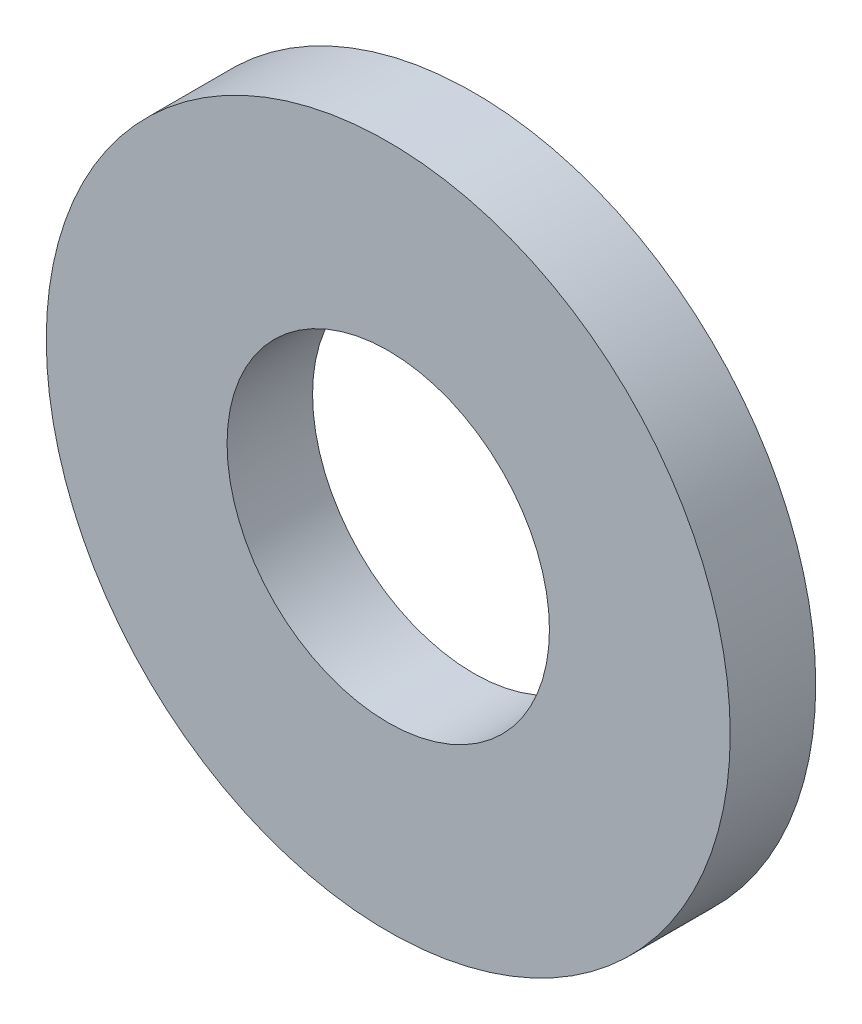
from build123d import *

# Parameters (mm, degrees)
SKETCH1_R           = 6.35
SKETCH1_R_2         = 2.99299376
BOSS_EXTRUDE1_DEPTH = 1.5875


with BuildPart() as part:
    # Sketch1 → Boss-Extrude1 (new body)
    with BuildSketch(Plane.XY):
        Circle(SKETCH1_R)
        Circle(SKETCH1_R_2, mode=Mode.SUBTRACT)
    extrude(amount=BOSS_EXTRUDE1_DEPTH)


solid = part.part
